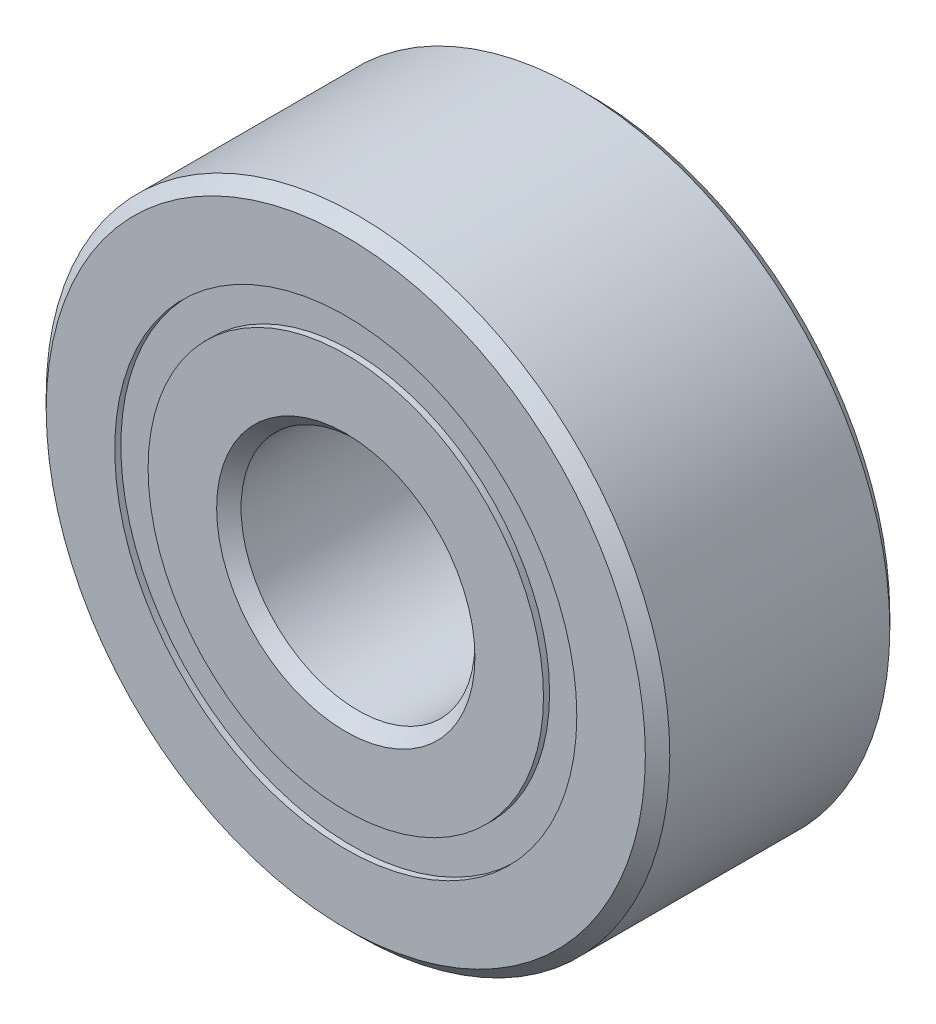
from build123d import *

# Parameters (mm, degrees)
CIRPATTERN1_COUNT = 8
SKETCH5_W         = 1.207534705
SKETCH5_H         = 0.678821978


with BuildPart() as part:
    # Sketch1 → Revolve1 (revolve)
    with BuildSketch(Plane(origin=(0, 0, 0), x_dir=(0, 0, -1), z_dir=(1, 0, 0))):
        with BuildLine():
            Line((2.24028, 6.35), (-2.24028, 6.35))
            Line((-2.24028, 6.35), (-2.4892, 6.10108))
            Line((-2.4892, 6.10108), (-2.4892, 4.705035989))
            Line((-2.4892, 4.705035989), (-1.106311111, 4.705035989))
            ThreePointArc((-1.106311111, 4.705035989), (0, 5.522830295), (1.106311111, 4.705035989))
            Line((1.106311111, 4.705035989), (2.4892, 4.705035989))
            Line((2.4892, 4.705035989), (2.4892, 6.10108))
            Line((2.4892, 6.10108), (2.24028, 6.35))
        make_face()
    revolve(axis=Axis((0, 0, 2.4892), (0, 0, -1)))


with BuildPart() as body_2:
    # Sketch3 → Revolve3 (revolve)
    with BuildSketch(Plane(origin=(0, 0, 0), x_dir=(0, 0, -1), z_dir=(1, 0, 0))):
        with BuildLine():
            Line((-2.4892, 4.026214011), (-1.106311111, 4.026214011))
            ThreePointArc((-1.106311111, 4.026214011), (0, 3.208419705), (1.106311111, 4.026214011))
            Line((1.106311111, 4.026214011), (2.4892, 4.026214011))
            Line((2.4892, 4.026214011), (2.4892, 2.63017))
            Line((2.4892, 2.63017), (2.24028, 2.38125))
            Line((2.24028, 2.38125), (-2.24028, 2.38125))
            Line((-2.24028, 2.38125), (-2.4892, 2.63017))
            Line((-2.4892, 2.63017), (-2.4892, 4.026214011))
        make_face()
    revolve(axis=Axis((0, 0, 2.4892), (0, 0, -1)))


with BuildPart() as body_3:
    # Sketch4 → Revolve4 (revolve)
    with BuildSketch(Plane(origin=(0, 0, 0), x_dir=(0, 0, -1), z_dir=(1, 0, 0))):
        with BuildLine():
            Line((-1.157205295, 4.365625), (1.157205295, 4.365625))
            ThreePointArc((1.157205295, 4.365625), (0, 5.522830295), (-1.157205295, 4.365625))
        make_face()
    revolve(axis=Axis((0, 4.365625, 1.157205295), (0, 0, -1)))


with BuildPart() as cirpattern1_1:
    # CirPattern1: pattern copy
    add(body_3.part.rotate(Axis((0, 0, 0), (0, 0, 1)), 1 * 360 / CIRPATTERN1_COUNT))


with BuildPart() as cirpattern1_2:
    # CirPattern1: pattern copy
    add(body_3.part.rotate(Axis((0, 0, 0), (0, 0, 1)), 2 * 360 / CIRPATTERN1_COUNT))


with BuildPart() as cirpattern1_3:
    # CirPattern1: pattern copy
    add(body_3.part.rotate(Axis((0, 0, 0), (0, 0, 1)), 3 * 360 / CIRPATTERN1_COUNT))


with BuildPart() as cirpattern1_4:
    # CirPattern1: pattern copy
    add(body_3.part.rotate(Axis((0, 0, 0), (0, 0, 1)), 4 * 360 / CIRPATTERN1_COUNT))


with BuildPart() as cirpattern1_5:
    # CirPattern1: pattern copy
    add(body_3.part.rotate(Axis((0, 0, 0), (0, 0, 1)), 5 * 360 / CIRPATTERN1_COUNT))


with BuildPart() as cirpattern1_6:
    # CirPattern1: pattern copy
    add(body_3.part.rotate(Axis((0, 0, 0), (0, 0, 1)), 6 * 360 / CIRPATTERN1_COUNT))


with BuildPart() as cirpattern1_7:
    # CirPattern1: pattern copy
    add(body_3.part.rotate(Axis((0, 0, 0), (0, 0, 1)), 7 * 360 / CIRPATTERN1_COUNT))


with BuildPart() as body_11:
    # Sketch5 → Revolve5 (revolve)
    with BuildSketch(Plane(origin=(0, 0, 0), x_dir=(0, 0, -1), z_dir=(1, 0, 0))):
        with Locations((-1.760972648, 4.365625)):
            Rectangle(SKETCH5_W, SKETCH5_H)
        with Locations((1.760972648, 4.365625)):
            Rectangle(SKETCH5_W, SKETCH5_H)
    revolve(axis=Axis((0, 0, 2.4892), (0, 0, -1)))


solid = Compound([part.part, body_2.part, body_3.part, cirpattern1_1.part, cirpattern1_2.part, cirpattern1_3.part, cirpattern1_4.part, cirpattern1_5.part, cirpattern1_6.part, cirpattern1_7.part, body_11.part])
